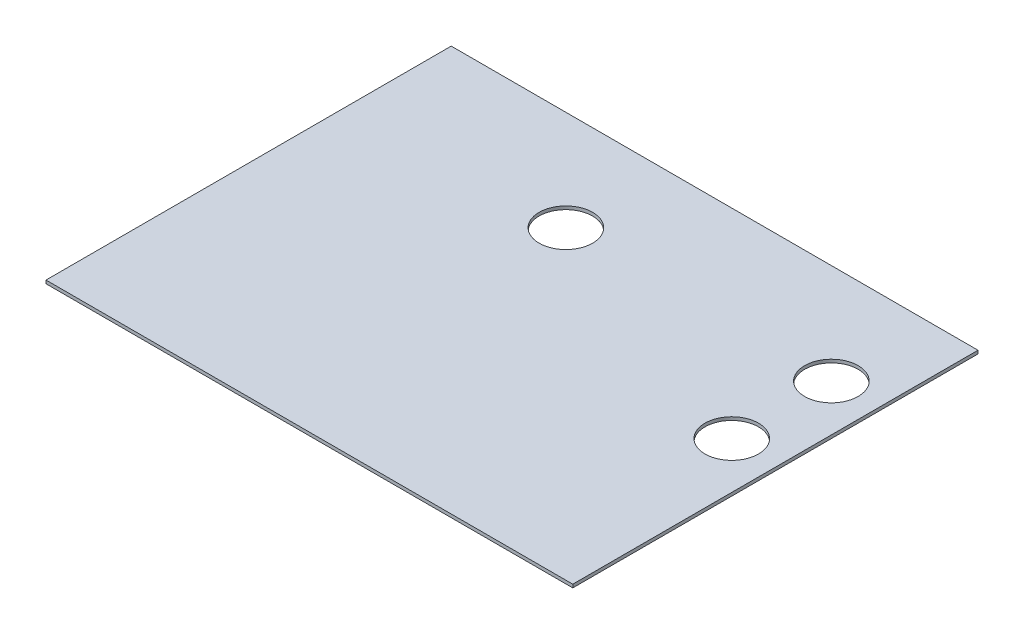
from build123d import *

# Parameters (mm, degrees)
SKETCH1_W           = 325
SKETCH1_H           = 250
BOSS_EXTRUDE1_DEPTH = 2
CUT_EXTRUDE1_REACH  = 4
SKETCH2_R           = 16.5


with BuildPart() as part:
    # Sketch1 → Boss-Extrude1 (new body)
    with BuildSketch(Plane(origin=(0, 0, 0), x_dir=(1, 0, 0), z_dir=(0, 1, 0))):
        Rectangle(SKETCH1_W, SKETCH1_H)
    extrude(amount=BOSS_EXTRUDE1_DEPTH)

    # Sketch2 → Cut-Extrude1 (cut, up to next)
    with BuildSketch(Plane(origin=(0, 2, 0), x_dir=(1, 0, 0), z_dir=(0, 1, 0)), mode=Mode.PRIVATE) as cut_extrude1_sk1:
        with Locations((133.736379862, 1.843557571)):
            Circle(SKETCH2_R)
    cut_extrude1_tool1 = extrude(cut_extrude1_sk1.sketch, amount=-CUT_EXTRUDE1_REACH, mode=Mode.PRIVATE) & part.part
    add(cut_extrude1_tool1.solids().sort_by_distance((133.73638, 2, -1.843558))[0], mode=Mode.SUBTRACT)
    # Sketch2 → Cut-Extrude1 (cut, up to next)
    with BuildSketch(Plane(origin=(0, 2, 0), x_dir=(1, 0, 0), z_dir=(0, 1, 0)), mode=Mode.PRIVATE) as cut_extrude1_sk2:
        with Locations((133.736379862, 63.311910549)):
            Circle(SKETCH2_R)
    cut_extrude1_tool2 = extrude(cut_extrude1_sk2.sketch, amount=-CUT_EXTRUDE1_REACH, mode=Mode.PRIVATE) & part.part
    add(cut_extrude1_tool2.solids().sort_by_distance((133.73638, 2, -63.311911))[0], mode=Mode.SUBTRACT)
    # Sketch2 → Cut-Extrude1 (cut, up to next)
    with BuildSketch(Plane(origin=(0, 2, 0), x_dir=(1, 0, 0), z_dir=(0, 1, 0)), mode=Mode.PRIVATE) as cut_extrude1_sk3:
        with Locations((-30.073468299, 63.311910549)):
            Circle(SKETCH2_R)
    cut_extrude1_tool3 = extrude(cut_extrude1_sk3.sketch, amount=-CUT_EXTRUDE1_REACH, mode=Mode.PRIVATE) & part.part
    add(cut_extrude1_tool3.solids().sort_by_distance((-30.073468, 2, -63.311911))[0], mode=Mode.SUBTRACT)


solid = part.part
